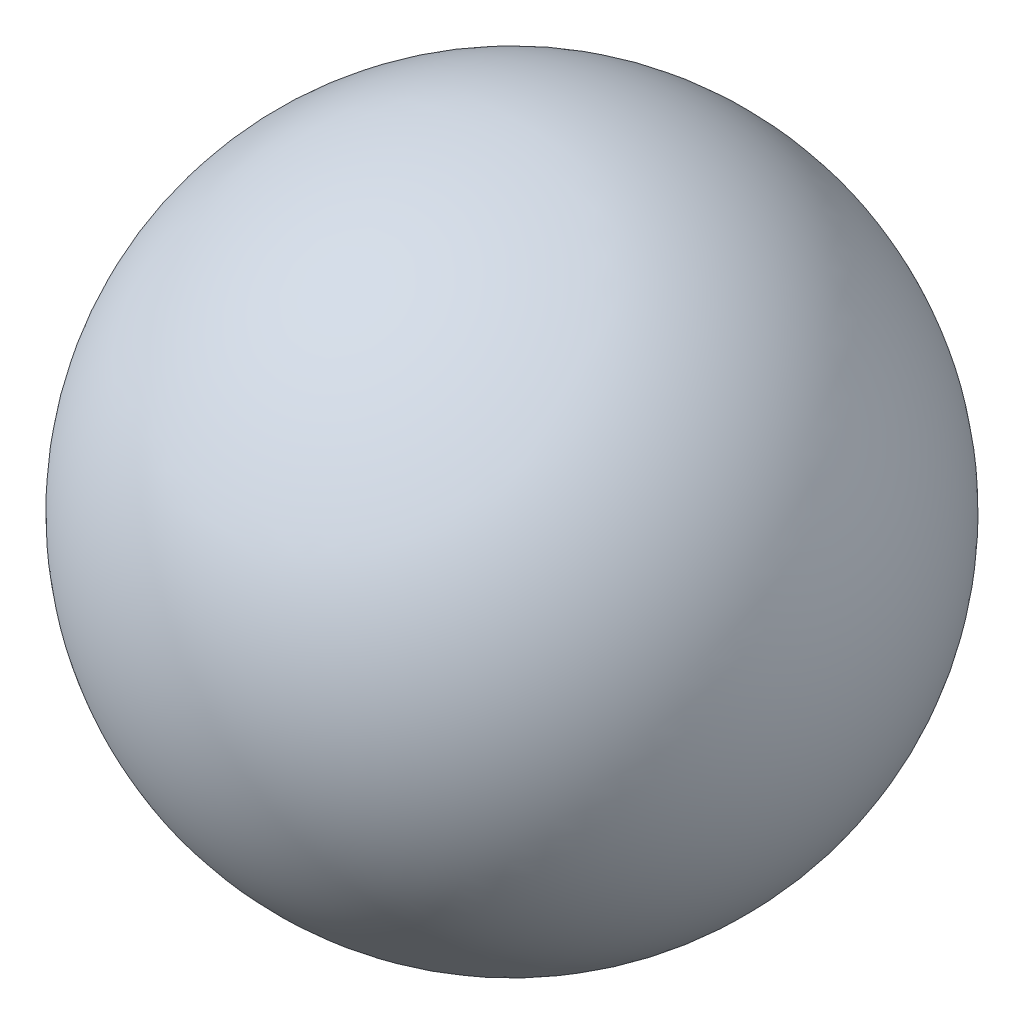
from build123d import *


with BuildPart() as part:
    # Sketch1 → Revolve1 (revolve)
    with BuildSketch(Plane(origin=(0, 0, 0), x_dir=(1, 0, 0), z_dir=(0, 1, 0))):
        with BuildLine():
            Line((0, 164.7), (0, -164.7))
            ThreePointArc((0, -164.7), (164.7, 0), (0, 164.7))
        make_face()
    revolve(axis=Axis((0, 0, -164.7), (0, 0, 1)))


solid = part.part
